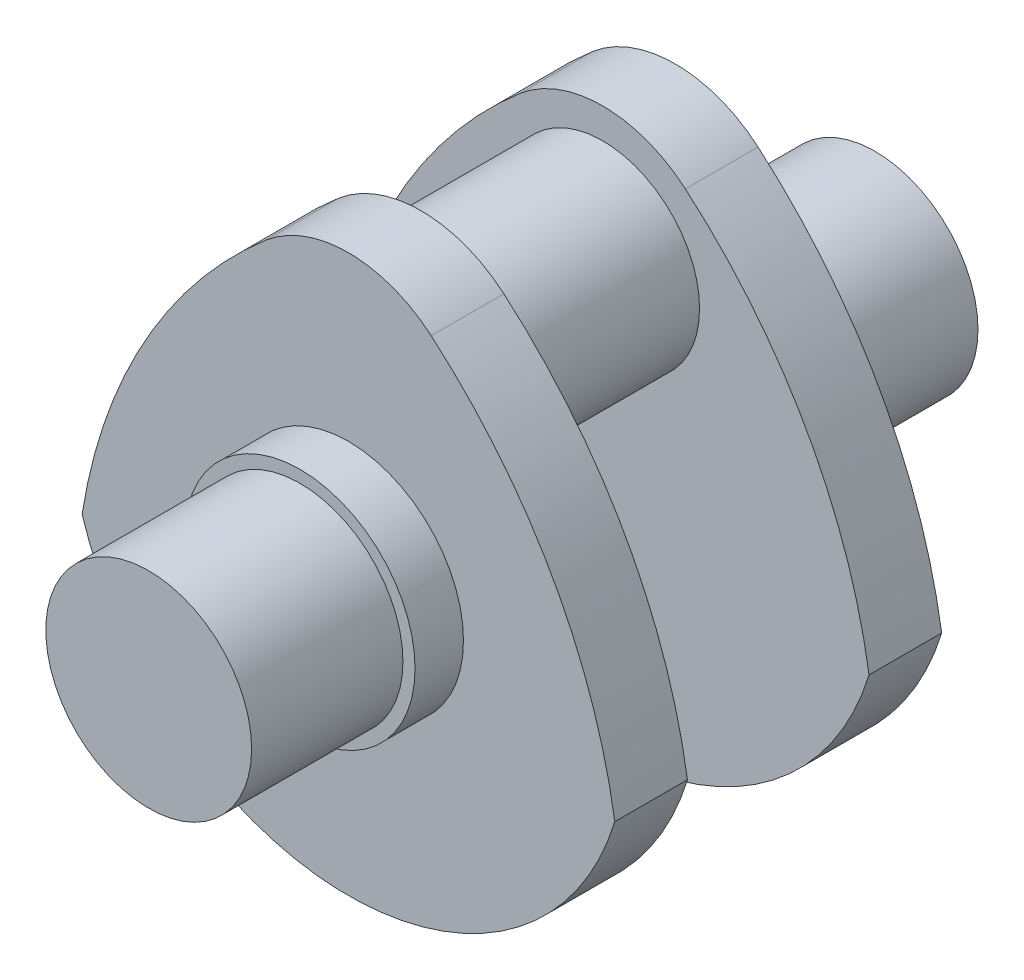
from build123d import *

# Parameters (mm, degrees)
SKETCH1_R           = 17
BOSS_EXTRUDE1_DEPTH = 25
SKETCH2_R           = 19
BOSS_EXTRUDE2_DEPTH = 8
BOSS_EXTRUDE3_DEPTH = 12
SKETCH6_R           = 16
BOSS_EXTRUDE4_DEPTH = 15


with BuildPart() as part:
    # Sketch1 → Boss-Extrude1 (new body)
    with BuildSketch(Plane.XY):
        Circle(SKETCH1_R)
    extrude(amount=BOSS_EXTRUDE1_DEPTH)

    # Sketch2 → Boss-Extrude2 (add)
    with BuildSketch(Plane.XY):
        Circle(SKETCH2_R)
    extrude(amount=-BOSS_EXTRUDE2_DEPTH)

    # Sketch5 → Boss-Extrude3 (add)
    with BuildSketch(Plane(origin=(0, 0, -8), x_dir=(-1, 0, 0), z_dir=(0, 0, -1))):
        with BuildLine():
            ThreePointArc((44, -13.416407865), (0, -46), (-44, -13.416407865))
            ThreePointArc((-44, -13.416407865), (-33.683444249, 16.469257624), (-13.668094758, 40.943123461))
            ThreePointArc((-13.668094758, 40.943123461), (0, 46), (13.668094758, 40.943123461))
            ThreePointArc((13.668094758, 40.943123461), (33.683444249, 16.469257624), (44, -13.416407865))
        make_face()
    extrude(amount=BOSS_EXTRUDE3_DEPTH)

    # Sketch6 → Boss-Extrude4 (add)
    with BuildSketch(Plane(origin=(0, 0, -20), x_dir=(-1, 0, 0), z_dir=(0, 0, -1))):
        with Locations((0, 25)):
            Circle(SKETCH6_R)
    extrude(amount=BOSS_EXTRUDE4_DEPTH)

    # Mirror2: part across plane


with BuildPart() as part_1:
    add(part.part)
    add(part.part.mirror(Plane(origin=(0, 25, -35), x_dir=(1, 0, 0), z_dir=(0, 0, -1))))


solid = part_1.part
